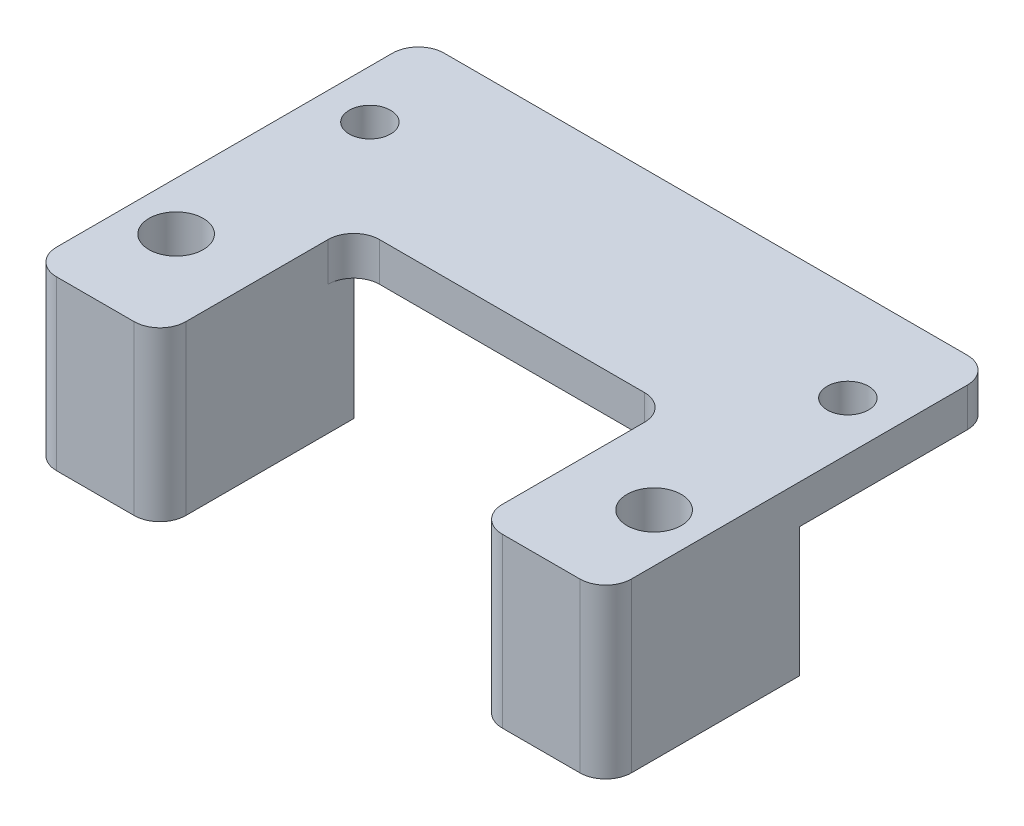
from build123d import *

# Parameters (mm, degrees)
SKETCH_1_W          = 44.5
SKETCH_1_H          = 30
EXTRUDE_1_DEPTH     = 3
SKETCH_2_W          = 10
SKETCH_2_H          = 15
EXTRUDE_2_DEPTH     = 10
SKETCH_3_R          = 2.1
SKETCH_3_R_2        = 1.6
CUT_EXTRUDE_1_DEPTH = 45
SKETCH_4_W          = 24.5
SKETCH_4_H          = 15
CUT_EXTRUDE_2_DEPTH = 10
FILLET_2_R          = 2


with BuildPart() as part:
    # ｽｹｯﾁ1 → ﾎﾞｽ - 押し出し1 (new body)
    with BuildSketch(Plane(origin=(0, 0, 0), x_dir=(1, 0, 0), z_dir=(0, 1, 0))):
        with Locations((22.25, 15)):
            Rectangle(SKETCH_1_W, SKETCH_1_H)
    extrude(amount=EXTRUDE_1_DEPTH)

    # ｽｹｯﾁ2 → ﾎﾞｽ - 押し出し2 (add)
    with BuildSketch(Plane(origin=(0, 0, 0), x_dir=(-1, 0, 0), z_dir=(0, -1, 0))):
        with Locations((-5, 7.5)):
            Rectangle(SKETCH_2_W, SKETCH_2_H)
        with Locations((-39.5, 7.5)):
            Rectangle(SKETCH_2_W, SKETCH_2_H)
    extrude(amount=EXTRUDE_2_DEPTH)

    # ｽｹｯﾁ3 → ｶｯﾄ - 押し出し1 (cut)
    with BuildSketch(Plane(origin=(0, 3, 0), x_dir=(1, 0, 0), z_dir=(0, 1, 0))):
        with Locations((3.75, 7.5)):
            Circle(SKETCH_3_R)
        with Locations((40.75, 7.5)):
            Circle(SKETCH_3_R)
        with Locations((40.75, 22.5)):
            Circle(SKETCH_3_R_2)
        with Locations((3.75, 22.5)):
            Circle(SKETCH_3_R_2)
    extrude(amount=-CUT_EXTRUDE_1_DEPTH, mode=Mode.SUBTRACT)

    # ｽｹｯﾁ4 → ｶｯﾄ - 押し出し2 (cut)
    with BuildSketch(Plane(origin=(0, 0, 0), x_dir=(-1, 0, 0), z_dir=(0, -1, 0))):
        with Locations((-22.25, 7.5)):
            Rectangle(SKETCH_4_W, SKETCH_4_H)
    extrude(amount=-CUT_EXTRUDE_2_DEPTH, mode=Mode.SUBTRACT)

    # ﾌｨﾚｯﾄ2
    fillet_2_edges = [part.edges().sort_by_distance(p)[0] for p in [
        (10, -3.5, 0),
        (34.5, -3.5, 0),
        (10, 1.5, -15),
        (34.5, 1.5, -15),
        (0, 1.5, -30),
        (44.5, 1.5, -30),
        (44.5, -3.5, 0),
        (0, -3.5, 0),
    ]]
    fillet(fillet_2_edges, radius=FILLET_2_R)


solid = part.part
